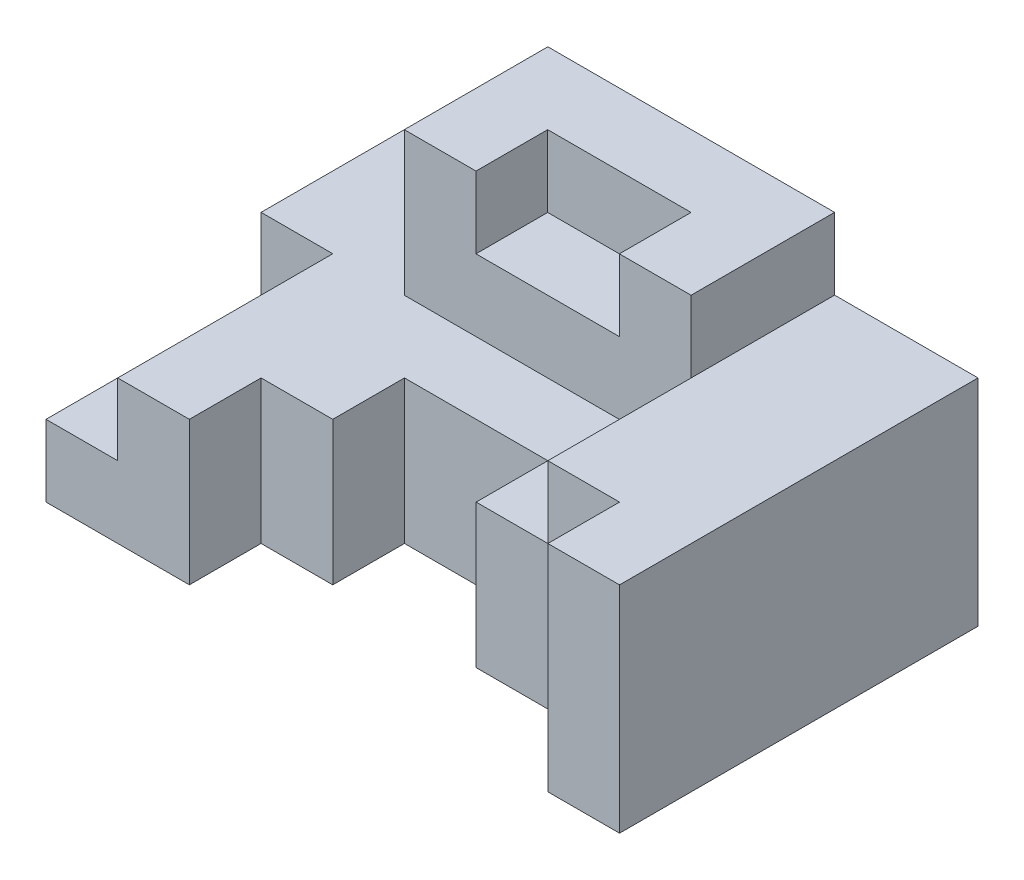
from build123d import *

# Parameters (mm, degrees)
SKETCH1_W           = 80
SKETCH1_H           = 50
BOSS_EXTRUDE1_DEPTH = 20
CUT_EXTRUDE1_DEPTH  = 20
SKETCH3_W           = 10
SKETCH3_H           = 30
CUT_EXTRUDE2_DEPTH  = 10
BOSS_EXTRUDE2_DEPTH = 10
SKETCH6_W           = 40
SKETCH6_H           = 20.022717562
BOSS_EXTRUDE3_DEPTH = 20
SKETCH7_W           = 20
SKETCH7_H           = 10
CUT_EXTRUDE3_DEPTH  = 10


with BuildPart() as part:
    # Sketch1 → Boss-Extrude1 (new body)
    with BuildSketch(Plane(origin=(0, 0, 0), x_dir=(1, 0, 0), z_dir=(0, 1, 0))):
        Rectangle(SKETCH1_W, SKETCH1_H)
    extrude(amount=BOSS_EXTRUDE1_DEPTH)

    # Sketch2 → Cut-Extrude1 (cut)
    with BuildSketch(Plane(origin=(0, 20, 0), x_dir=(1, 0, 0), z_dir=(0, 1, 0))):
        Polygon((-20, -25), (-20, -15), (-10, -15), (-10, -5), (10, -5), (10, -15), (30, -15), (30, -25), align=None)
    extrude(amount=-CUT_EXTRUDE1_DEPTH, mode=Mode.SUBTRACT)

    # Sketch3 → Cut-Extrude2 (cut)
    with BuildSketch(Plane(origin=(0, 20, 0), x_dir=(1, 0, 0), z_dir=(0, 1, 0))):
        with Locations((-35, -10)):
            Rectangle(SKETCH3_W, SKETCH3_H)
    extrude(amount=-CUT_EXTRUDE2_DEPTH, mode=Mode.SUBTRACT)

    # Sketch4 → Boss-Extrude2 (add)
    with BuildSketch(Plane(origin=(0, 20, 0), x_dir=(1, 0, 0), z_dir=(0, 1, 0))):
        Polygon((40, -25), (40, 25), (20, 25), (20, -15), (30, -15), (30, -25), align=None)
    extrude(amount=BOSS_EXTRUDE2_DEPTH)

    # Sketch6 → Boss-Extrude3 (add)
    with BuildSketch(Plane(origin=(0, 20, 0), x_dir=(1, 0, 0), z_dir=(0, 1, 0))):
        with Locations((0, 14.988641219)):
            Rectangle(SKETCH6_W, SKETCH6_H)
    extrude(amount=BOSS_EXTRUDE3_DEPTH)

    # Sketch7 → Cut-Extrude3 (cut)
    with BuildSketch(Plane(origin=(0, 40, 0), x_dir=(1, 0, 0), z_dir=(0, 1, 0))):
        with Locations((0, 9.977282438)):
            Rectangle(SKETCH7_W, SKETCH7_H)
    extrude(amount=-CUT_EXTRUDE3_DEPTH, mode=Mode.SUBTRACT)


solid = part.part
